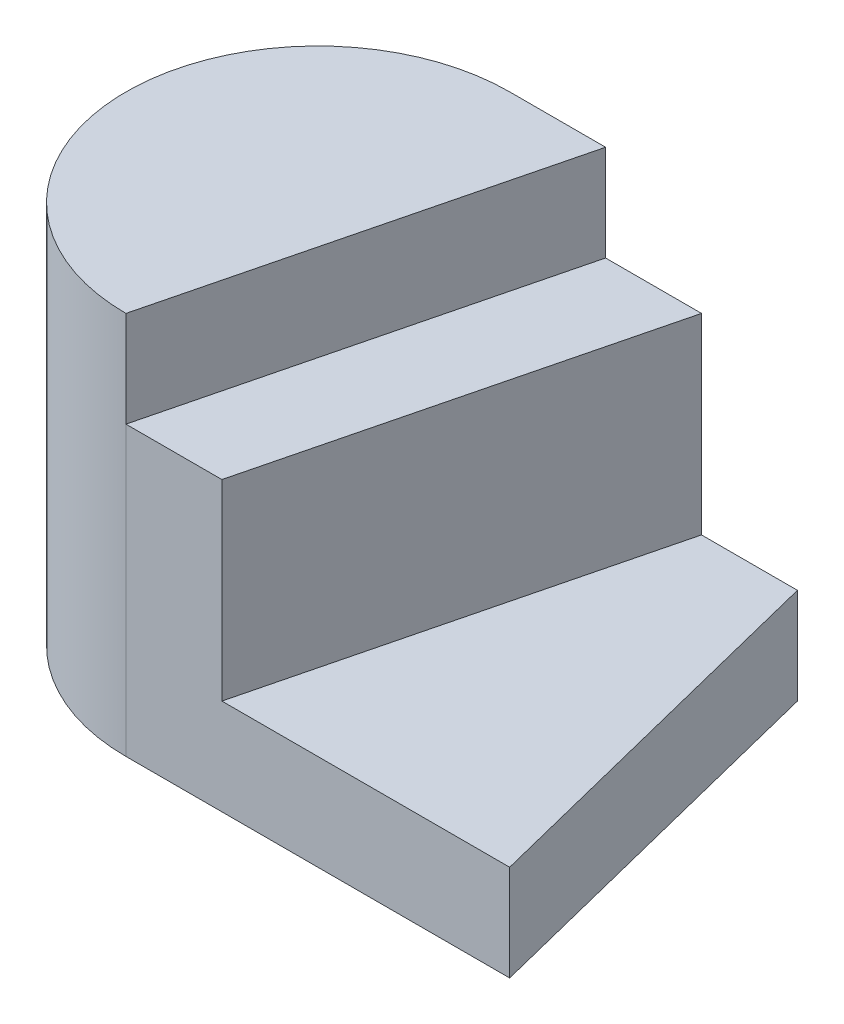
from build123d import *

# Parameters (mm, degrees)
EXTRUDE_2_DEPTH = 20
EXTRUDE_3_DEPTH = 15
EXTRUDE_4_DEPTH = 5


with BuildPart() as part:
    # 草圖1 → 填料-伸長2 (new body)
    with BuildSketch(Plane(origin=(0, 0, 0), x_dir=(1, 0, 0), z_dir=(0, 1, 0))):
        with BuildLine():
            Line((5, 10), (0, 10))
            ThreePointArc((0, 10), (-10, 0), (0, -10))
            Line((0, -10), (5, 10))
        make_face()
    extrude(amount=EXTRUDE_2_DEPTH)

    # 草圖1<4> → 填料-伸長3 (add)
    with BuildSketch(Plane(origin=(0, 0, 0), x_dir=(1, 0, 0), z_dir=(0, 1, 0))):
        Polygon((5, 10), (0, -10), (5, -10), (10, 10), align=None)
    extrude(amount=EXTRUDE_3_DEPTH)

    # 草圖1<5> → 填料-伸長4 (add)
    with BuildSketch(Plane(origin=(0, 0, 0), x_dir=(1, 0, 0), z_dir=(0, 1, 0))):
        Polygon((10, 10), (5, -10), (20, -10), (15, 10), align=None)
    extrude(amount=EXTRUDE_4_DEPTH)


solid = part.part
